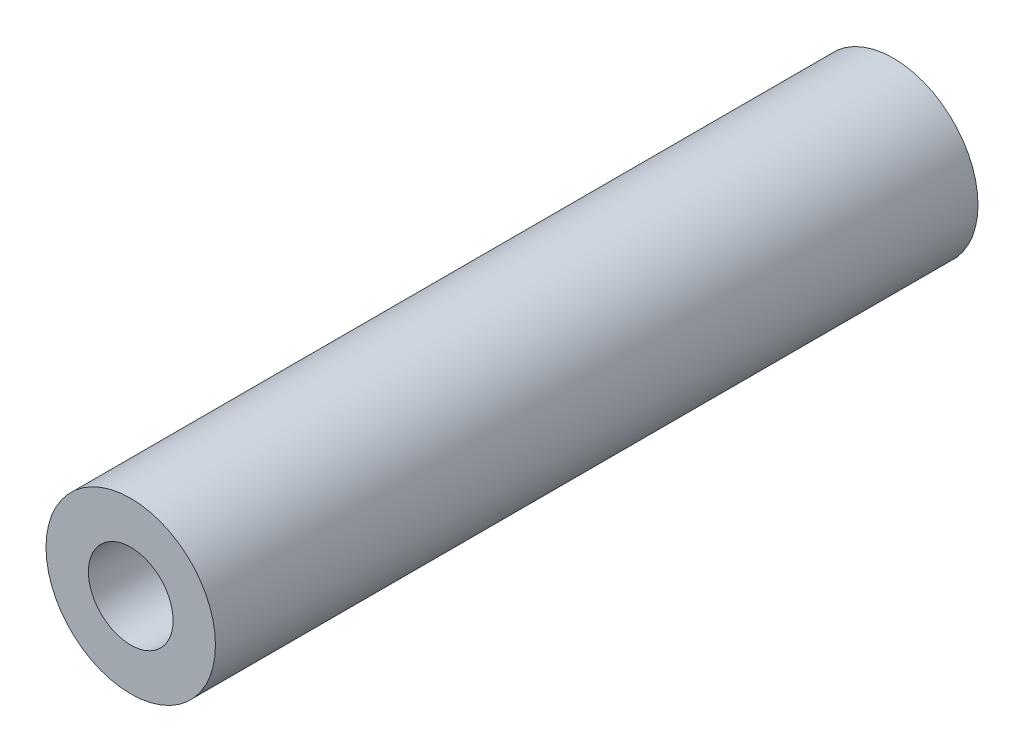
from build123d import *

# Parameters (mm, degrees)
SKETCH_1_R      = 4
SKETCH_1_R_2    = 2
EXTRUDE_1_DEPTH = 36


with BuildPart() as part:
    # ｽｹｯﾁ1 → ﾎﾞｽ - 押し出し1 (new body)
    with BuildSketch(Plane.XY):
        Circle(SKETCH_1_R)
        Circle(SKETCH_1_R_2, mode=Mode.SUBTRACT)
    extrude(amount=EXTRUDE_1_DEPTH)


solid = part.part
